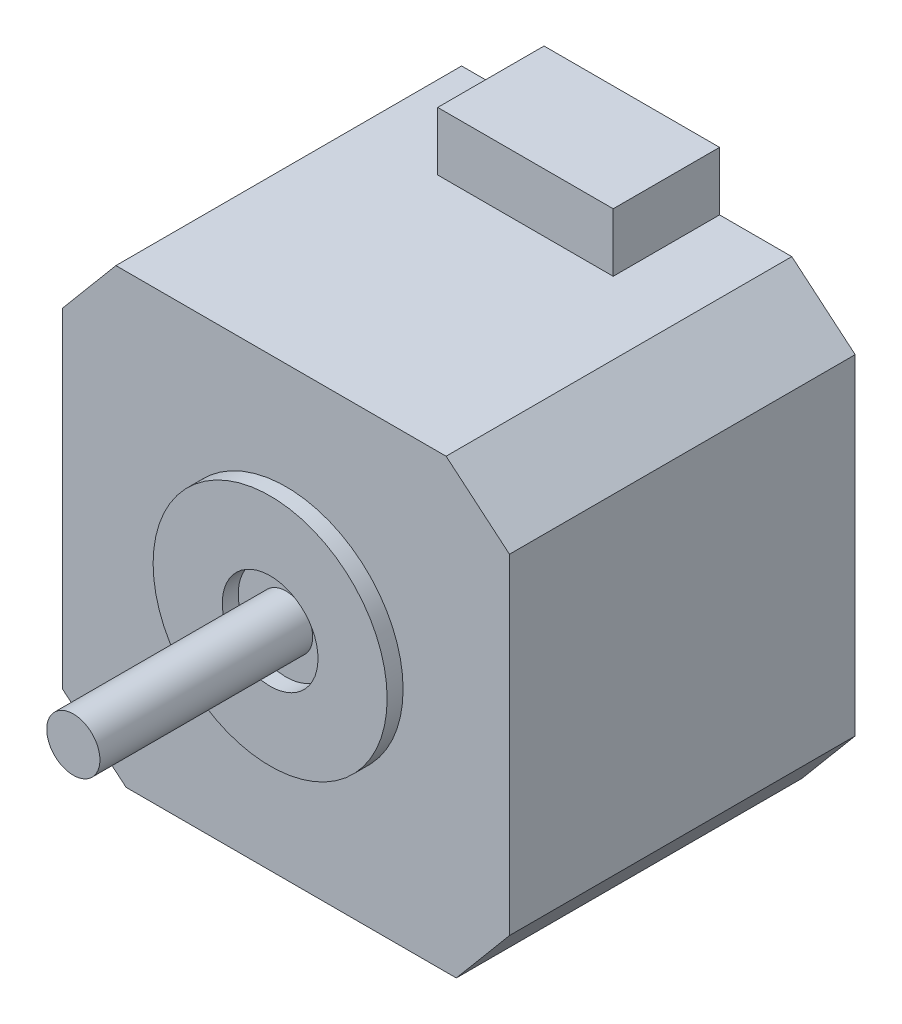
from build123d import *

# Parameters (mm, degrees)
ESQUISSE1_W             = 42
ESQUISSE1_H             = 42
BOSS_EXTRU_1_DEPTH      = 32.5
CHANFREIN1_SIZE         = 5
CHANFREIN1_SIZE2        = 5.958767963
CHANFREIN1_PART_2_SIZE  = 5
CHANFREIN1_PART_2_SIZE2 = 5.958767963
CHANFREIN1_PART_3_SIZE  = 5
CHANFREIN1_PART_3_SIZE2 = 5.958767963
CHANFREIN1_PART_4_SIZE  = 5
CHANFREIN1_PART_4_SIZE2 = 5.958767963
ESQUISSE2_R             = 11
ESQUISSE2_R_2           = 4.5
BOSS_EXTRU_2_DEPTH      = 1.5
ESQUISSE3_R             = 2.5
BOSS_EXTRU_3_DEPTH      = 20
BOSS_EXTRU_4_DEPTH      = 5.5


with BuildPart() as part:
    # Esquisse1 → Boss.-Extru.1 (new body)
    with BuildSketch(Plane.XY):
        Rectangle(ESQUISSE1_W, ESQUISSE1_H)
    extrude(amount=BOSS_EXTRU_1_DEPTH)

    # Chanfrein1
    chanfrein1_edges = [part.edges().sort_by_distance(p)[0] for p in [
        (21, -21, 16.25),
    ]]
    chanfrein1_side = [part.faces().sort_by_distance(p)[0] for p in [
        (0, -21, 16.25),
    ]]
    chamfer(chanfrein1_edges, length=CHANFREIN1_SIZE, length2=CHANFREIN1_SIZE2, reference=chanfrein1_side[0])

    # Chanfrein1 part 2
    chanfrein1_part_2_edges = [part.edges().sort_by_distance(p)[0] for p in [
        (-21, -21, 16.25),
    ]]
    chanfrein1_part_2_side = [part.faces().sort_by_distance(p)[0] for p in [
        (-21, 0, 16.25),
    ]]
    chamfer(chanfrein1_part_2_edges, length=CHANFREIN1_PART_2_SIZE, length2=CHANFREIN1_PART_2_SIZE2, reference=chanfrein1_part_2_side[0])

    # Chanfrein1 part 3
    chanfrein1_part_3_edges = [part.edges().sort_by_distance(p)[0] for p in [
        (-21, 21, 16.25),
    ]]
    chanfrein1_part_3_side = [part.faces().sort_by_distance(p)[0] for p in [
        (0, 21, 16.25),
    ]]
    chamfer(chanfrein1_part_3_edges, length=CHANFREIN1_PART_3_SIZE, length2=CHANFREIN1_PART_3_SIZE2, reference=chanfrein1_part_3_side[0])

    # Chanfrein1 part 4
    chanfrein1_part_4_edges = [part.edges().sort_by_distance(p)[0] for p in [
        (21, 21, 16.25),
    ]]
    chanfrein1_part_4_side = [part.faces().sort_by_distance(p)[0] for p in [
        (21, 0, 16.25),
    ]]
    chamfer(chanfrein1_part_4_edges, length=CHANFREIN1_PART_4_SIZE, length2=CHANFREIN1_PART_4_SIZE2, reference=chanfrein1_part_4_side[0])

    # Esquisse2 → Boss.-Extru.2 (add)
    with BuildSketch(Plane.XY.offset(32.5)):
        Circle(ESQUISSE2_R)
        Circle(ESQUISSE2_R_2, mode=Mode.SUBTRACT)
    extrude(amount=BOSS_EXTRU_2_DEPTH)

    # Esquisse3 → Boss.-Extru.3 (add)
    with BuildSketch(Plane.XY.offset(32.5)):
        Circle(ESQUISSE3_R)
    extrude(amount=BOSS_EXTRU_3_DEPTH)

    # Esquisse4 → Boss.-Extru.4 (add)
    with BuildSketch(Plane(origin=(0, 21, 0), x_dir=(1, 0, 0), z_dir=(0, 1, 0))):
        Polygon((0, 0), (8.25, 0), (8.25, -10), (-8.25, -10), (-8.25, 0), align=None)
    extrude(amount=BOSS_EXTRU_4_DEPTH)


solid = part.part
